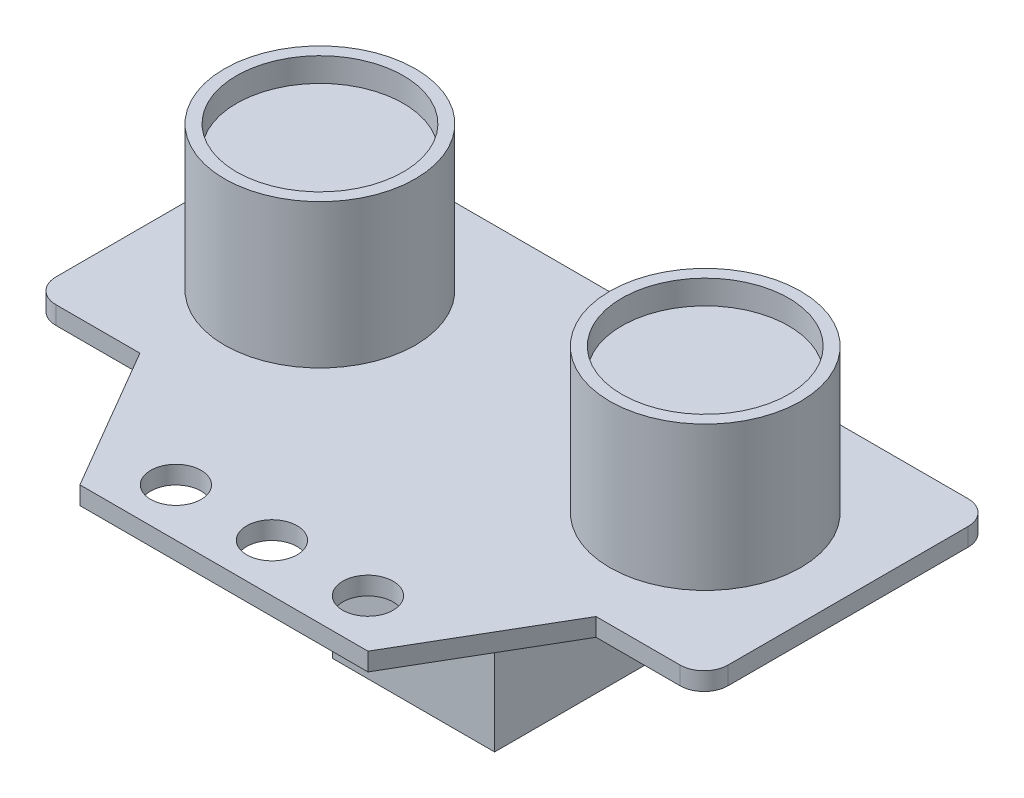
from build123d import *

# Parameters (mm, degrees)
SKETCH1_R           = 2.1
BOSS_EXTRUDE1_DEPTH = 1.5
FILLET1_R           = 2
SKETCH2_R           = 7.95
BOSS_EXTRUDE2_DEPTH = 12
SKETCH3_W           = 13.5
SKETCH3_H           = 16
BOSS_EXTRUDE3_DEPTH = 16.3
SKETCH4_R           = 6.95
CUT_EXTRUDE1_DEPTH  = 2


with BuildPart() as part:
    # Sketch1 → Boss-Extrude1 (new body)
    with BuildSketch(Plane(origin=(0, 0, 0), x_dir=(1, 0, 0), z_dir=(0, 1, 0))):
        Polygon((12, 0), (-12, 0), (-19, 12), (-28, 12), (-28, 36), (28, 36), (28, 12), (19, 12), align=None)
        with Locations((0, 4)):
            Circle(SKETCH1_R, mode=Mode.SUBTRACT)
        with Locations((-8, 4)):
            Circle(SKETCH1_R, mode=Mode.SUBTRACT)
        with Locations((8, 4)):
            Circle(SKETCH1_R, mode=Mode.SUBTRACT)
    extrude(amount=BOSS_EXTRUDE1_DEPTH)

    # Fillet1
    fillet1_edges = [part.edges().sort_by_distance(p)[0] for p in [
        (-28, 0.75, -12),
        (-28, 0.75, -36),
        (28, 0.75, -36),
        (28, 0.75, -12),
    ]]
    fillet(fillet1_edges, radius=FILLET1_R)

    # Sketch2 → Boss-Extrude2 (add)
    with BuildSketch(Plane(origin=(0, 1.5, 0), x_dir=(1, 0, 0), z_dir=(0, 1, 0))):
        with Locations((-16.05, 24.05)):
            Circle(SKETCH2_R)
        with Locations((16.05, 24.05)):
            Circle(SKETCH2_R)
    extrude(amount=BOSS_EXTRUDE2_DEPTH)

    # Sketch3 → Boss-Extrude3 (add)
    with BuildSketch(Plane.XZ):
        with Locations((0, -23.8)):
            Rectangle(SKETCH3_W, SKETCH3_H)
    extrude(amount=BOSS_EXTRUDE3_DEPTH)

    # Sketch4 → Cut-Extrude1 (cut)
    with BuildSketch(Plane(origin=(0, 13.5, 0), x_dir=(1, 0, 0), z_dir=(0, 1, 0))):
        with Locations((-16.05, 24.05)):
            Circle(SKETCH4_R)
        with Locations((16.05, 24.05)):
            Circle(SKETCH4_R)
    extrude(amount=-CUT_EXTRUDE1_DEPTH, mode=Mode.SUBTRACT)


solid = part.part
